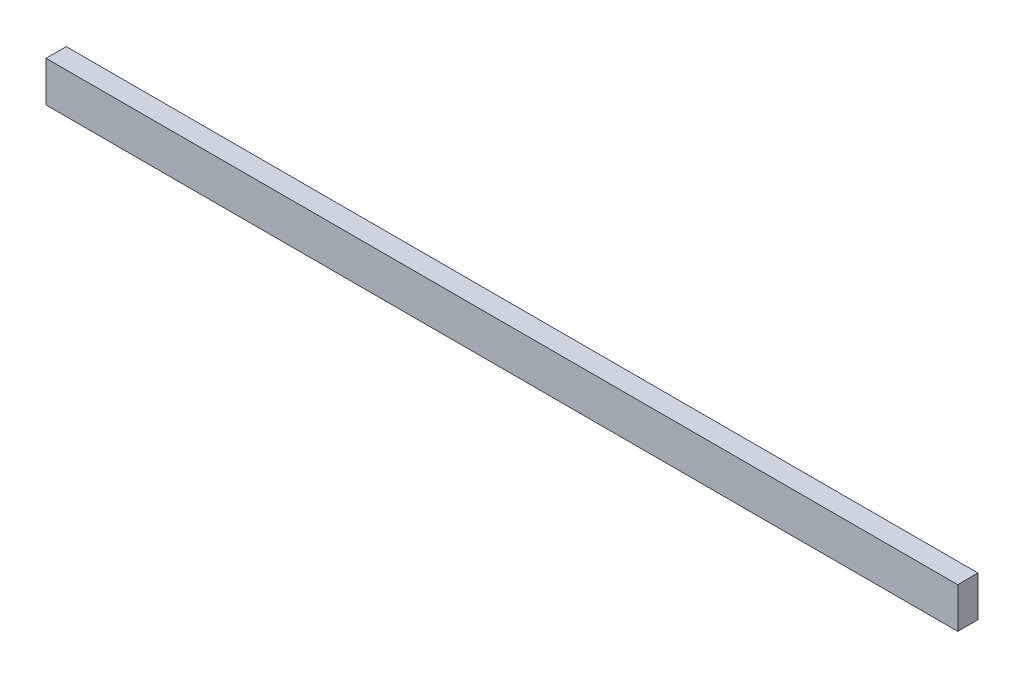
from build123d import *

# Parameters (mm, degrees)
ESQUISSE1_W        = 676
ESQUISSE1_H        = 30
BOSS_EXTRU_1_DEPTH = 15


with BuildPart() as part:
    # Esquisse1 → Boss.-Extru.1 (new body)
    with BuildSketch(Plane.XY):
        Rectangle(ESQUISSE1_W, ESQUISSE1_H)
    extrude(amount=BOSS_EXTRU_1_DEPTH)


solid = part.part
